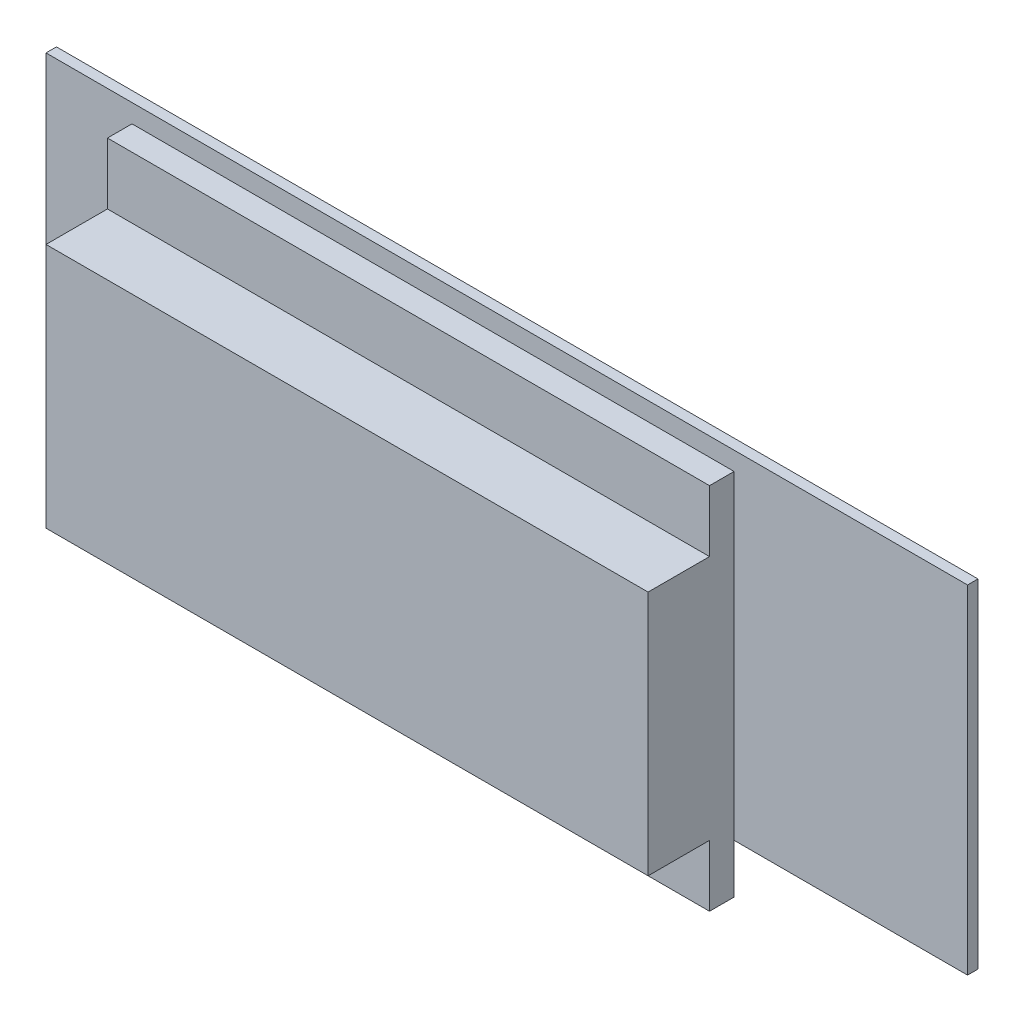
from build123d import *

# Parameters (mm, degrees)
SCHIZZO1_W                   = 150
SCHIZZO1_H                   = 55
ESTRUSIONE_ESTRUSIONE1_DEPTH = 1.7
SCHIZZO2_W                   = 98
SCHIZZO2_H                   = 60
ESTRUSIONE_ESTRUSIONE2_DEPTH = 4
SCHIZZO3_W                   = 98
SCHIZZO3_H                   = 40
ESTRUSIONE_ESTRUSIONE3_DEPTH = 10


with BuildPart() as part:
    # Schizzo1 → Estrusione-Estrusione1 (new body)
    with BuildSketch(Plane.XY):
        Rectangle(SCHIZZO1_W, SCHIZZO1_H)
    extrude(amount=ESTRUSIONE_ESTRUSIONE1_DEPTH)

    # Schizzo2 → Estrusione-Estrusione2 (add)
    with BuildSketch(Plane.XY.offset(1.7)):
        with Locations((-12, -5.5)):
            Rectangle(SCHIZZO2_W, SCHIZZO2_H)
    extrude(amount=ESTRUSIONE_ESTRUSIONE2_DEPTH)

    # Schizzo3 → Estrusione-Estrusione3 (add)
    with BuildSketch(Plane.XY.offset(5.7)):
        with Locations((-12, -5.5)):
            Rectangle(SCHIZZO3_W, SCHIZZO3_H)
    extrude(amount=ESTRUSIONE_ESTRUSIONE3_DEPTH)


solid = part.part
